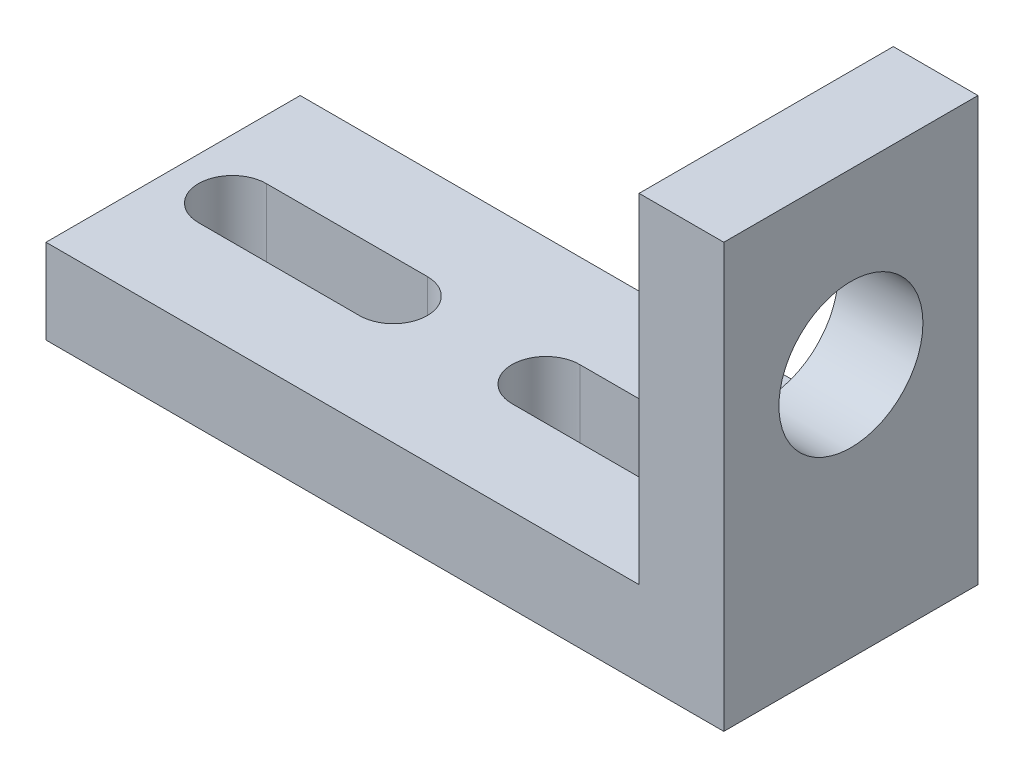
from build123d import *

# Parameters (mm, degrees)
CROQUIS1_W              = 40
CROQUIS1_H              = 15
SALIENTE_EXTRUIR1_DEPTH = 5
CROQUIS2_W              = 5
CROQUIS2_H              = 15
SALIENTE_EXTRUIR2_DEPTH = 20
CROQUIS3_R              = 4.25
CORTAR_EXTRUIR1_DEPTH   = 20
CORTAR_EXTRUIR2_DEPTH   = 20


with BuildPart() as part:
    # Croquis1 → Saliente-Extruir1 (new body)
    with BuildSketch(Plane(origin=(0, 0, 0), x_dir=(1, 0, 0), z_dir=(0, 1, 0))):
        Rectangle(CROQUIS1_W, CROQUIS1_H)
    extrude(amount=SALIENTE_EXTRUIR1_DEPTH)

    # Croquis2 → Saliente-Extruir2 (add)
    with BuildSketch(Plane(origin=(0, 5, 0), x_dir=(1, 0, 0), z_dir=(0, 1, 0))):
        with Locations((17.5, 0)):
            Rectangle(CROQUIS2_W, CROQUIS2_H)
    extrude(amount=SALIENTE_EXTRUIR2_DEPTH)

    # Croquis3 → Cortar-Extruir1 (cut)
    with BuildSketch(Plane(origin=(20, 0, 0), x_dir=(0, 0, -1), z_dir=(1, 0, 0))):
        with Locations((0, 15)):
            Circle(CROQUIS3_R)
    extrude(amount=-CORTAR_EXTRUIR1_DEPTH, mode=Mode.SUBTRACT)

    # Croquis4 → Cortar-Extruir2 (cut)
    with BuildSketch(Plane(origin=(0, 5, 0), x_dir=(1, 0, 0), z_dir=(0, 1, 0))):
        with BuildLine():
            Line((-16.5, 2), (-7, 2))
            ThreePointArc((-7, 2), (-5, 0), (-7, -2))
            Line((-7, -2), (-16.5, -2))
            ThreePointArc((-16.5, -2), (-18.5, 0), (-16.5, 2))
        make_face()
        with BuildLine():
            Line((11.5, -2), (2, -2))
            ThreePointArc((2, -2), (0, 0), (2, 2))
            Line((2, 2), (11.5, 2))
            ThreePointArc((11.5, 2), (13.5, 0), (11.5, -2))
        make_face()
    extrude(amount=-CORTAR_EXTRUIR2_DEPTH, mode=Mode.SUBTRACT)


solid = part.part
